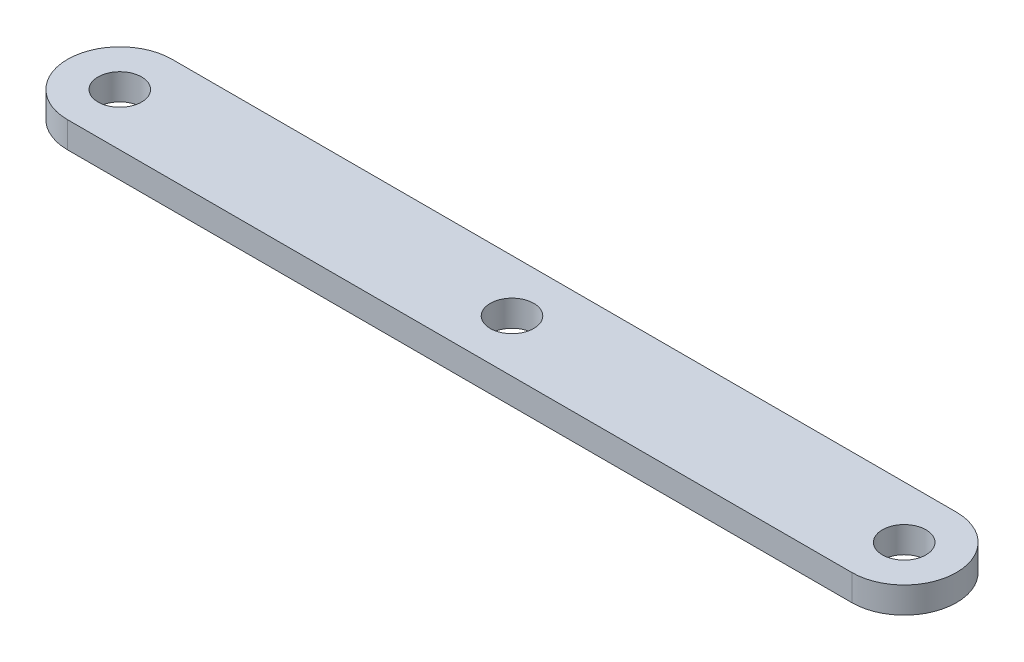
from build123d import *

# Parameters (mm, degrees)
EXTRUDE_1_DEPTH     = 3
CUT_EXTRUDE_1_REACH = 5
SKETCH_2_R          = 2.5


with BuildPart() as part:
    # 草圖1 → 填料-伸長1 (new body)
    with BuildSketch(Plane(origin=(0, 0, 0), x_dir=(1, 0, 0), z_dir=(0, 1, 0))):
        with BuildLine():
            Line((-45, 6), (45, 6))
            ThreePointArc((45, 6), (51, 0), (45, -6))
            Line((45, -6), (-45, -6))
            ThreePointArc((-45, -6), (-51, 0), (-45, 6))
        make_face()
    extrude(amount=EXTRUDE_1_DEPTH)

    # 草圖2 → 除料-伸長1 (cut, up to next)
    with BuildSketch(Plane(origin=(0, 3, 0), x_dir=(1, 0, 0), z_dir=(0, 1, 0)), mode=Mode.PRIVATE) as cut_extrude_1_sk1:
        with Locations((-45, 0)):
            Circle(SKETCH_2_R)
    cut_extrude_1_tool1 = extrude(cut_extrude_1_sk1.sketch, amount=-CUT_EXTRUDE_1_REACH, mode=Mode.PRIVATE) & part.part
    add(cut_extrude_1_tool1.solids().sort_by_distance((-45, 3, 0))[0], mode=Mode.SUBTRACT)
    # 草圖2 → 除料-伸長1 (cut, up to next)
    with BuildSketch(Plane(origin=(0, 3, 0), x_dir=(1, 0, 0), z_dir=(0, 1, 0)), mode=Mode.PRIVATE) as cut_extrude_1_sk2:
        with Locations((45, 0)):
            Circle(SKETCH_2_R)
    cut_extrude_1_tool2 = extrude(cut_extrude_1_sk2.sketch, amount=-CUT_EXTRUDE_1_REACH, mode=Mode.PRIVATE) & part.part
    add(cut_extrude_1_tool2.solids().sort_by_distance((45, 3, 0))[0], mode=Mode.SUBTRACT)
    # 草圖2 → 除料-伸長1 (cut, up to next)
    with BuildSketch(Plane(origin=(0, 3, 0), x_dir=(1, 0, 0), z_dir=(0, 1, 0)), mode=Mode.PRIVATE) as cut_extrude_1_sk3:
        Circle(SKETCH_2_R)
    cut_extrude_1_tool3 = extrude(cut_extrude_1_sk3.sketch, amount=-CUT_EXTRUDE_1_REACH, mode=Mode.PRIVATE) & part.part
    add(cut_extrude_1_tool3.solids().sort_by_distance((0, 3, 0))[0], mode=Mode.SUBTRACT)


solid = part.part
